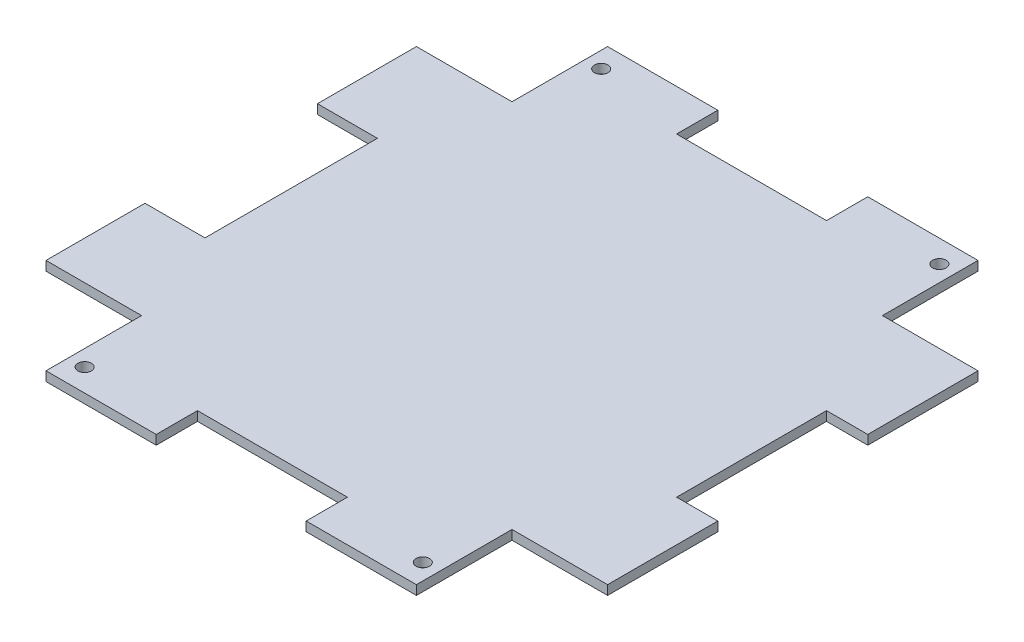
from build123d import *

# Parameters (mm, degrees)
BOSS_EXTRUDE1_DEPTH = 3.175
SKETCH2_R           = 2.286
CUT_EXTRUDE1_DEPTH  = 4.175
SKETCH3_W           = 20.32
SKETCH3_H           = 58.42
SKETCH3_W_2         = 50.8
SKETCH3_H_2         = 13.97
SKETCH3_W_3         = 13.97
SKETCH3_H_3         = 50.8
CUT_EXTRUDE2_DEPTH  = 4.175


with BuildPart() as part:
    # Sketch1 → Boss-Extrude1 (new body)
    with BuildSketch(Plane(origin=(0, 0, 0), x_dir=(1, 0, 0), z_dir=(0, 1, 0))):
        Polygon((-62.22816, -68.31704), (-29.84616, -68.31704), (-29.84616, -100.69904), (95.63984, -100.69904), (95.63984, -68.31704), (128.02184, -68.31704), (128.02184, 57.16896), (95.63984, 57.16896), (95.63984, 89.55096), (-29.84616, 89.55096), (-29.84616, 57.16896), (-62.22816, 57.16896), align=None)
    extrude(amount=BOSS_EXTRUDE1_DEPTH)

    # Sketch2 → Cut-Extrude1 (cut, through all)
    with BuildSketch(Plane(origin=(0, 3.175, 0), x_dir=(1, 0, 0), z_dir=(0, 1, 0))):
        with Locations((-24.38516, 81.93096)):
            Circle(SKETCH2_R)
        with Locations((90.17884, 81.93096)):
            Circle(SKETCH2_R)
        with Locations((90.17884, -93.07904)):
            Circle(SKETCH2_R)
        with Locations((-24.38516, -93.07904)):
            Circle(SKETCH2_R)
    extrude(amount=-CUT_EXTRUDE1_DEPTH, mode=Mode.SUBTRACT)

    # Sketch3 → Cut-Extrude2 (cut, through all)
    with BuildSketch(Plane(origin=(0, 3.175, 0), x_dir=(1, 0, 0), z_dir=(0, 1, 0))):
        with Locations((-52.06816, -5.57404)):
            Rectangle(SKETCH3_W, SKETCH3_H)
        with Locations((32.89684, 82.56596)):
            Rectangle(SKETCH3_W_2, SKETCH3_H_2)
        with Locations((121.03684, -5.57404)):
            Rectangle(SKETCH3_W_3, SKETCH3_H_3)
        with Locations((32.89684, -93.71404)):
            Rectangle(SKETCH3_W_2, SKETCH3_H_2)
    extrude(amount=-CUT_EXTRUDE2_DEPTH, mode=Mode.SUBTRACT)


solid = part.part
